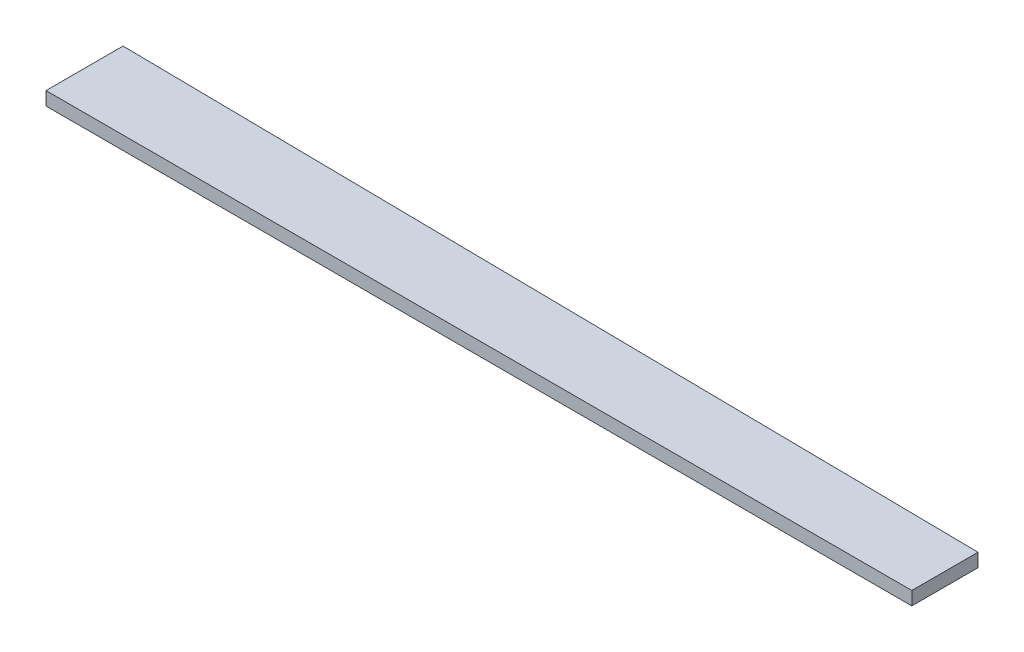
from build123d import *

# Parameters (mm, degrees)
BOSS_EXTRU_1_DEPTH = 2


with BuildPart() as part:
    # Esquisse1 → Boss.-Extru.1 (new body)
    with BuildSketch(Plane(origin=(0, 0, 0), x_dir=(1, 0, 0), z_dir=(0, 1, 0))):
        Polygon((0, 11.488054861), (0, 0), (129.087879033, 0), (129.087879033, 9.865274508), align=None)
    extrude(amount=BOSS_EXTRU_1_DEPTH)


solid = part.part
